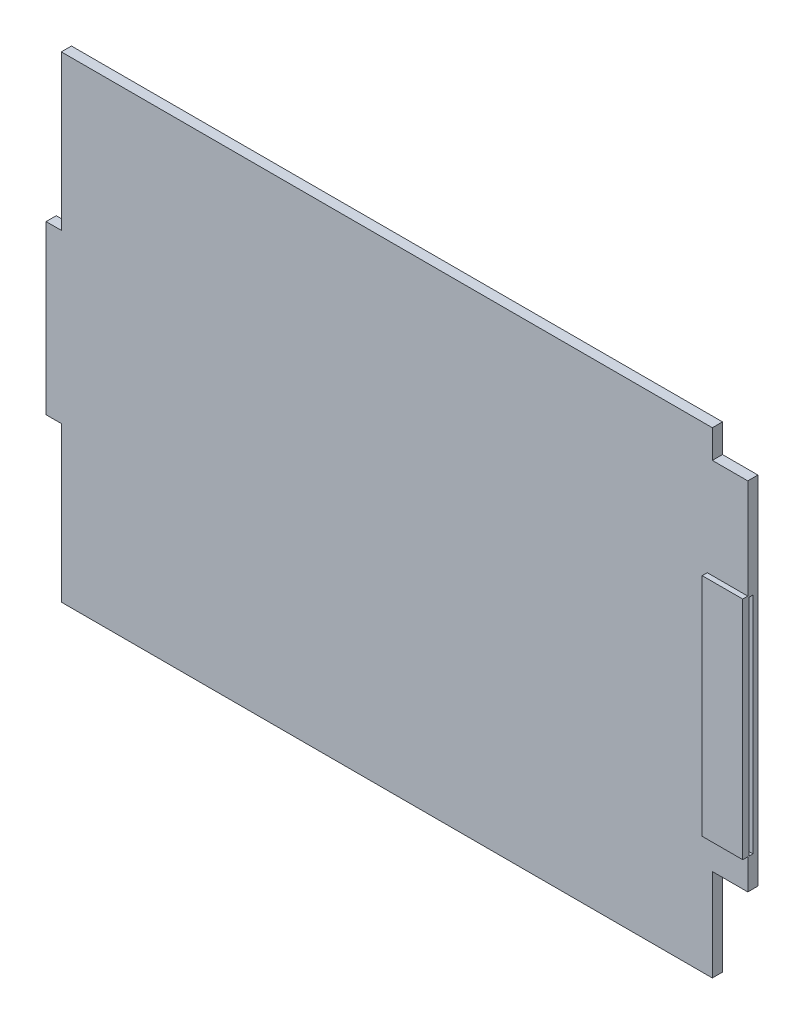
from build123d import *

# Parameters (mm, degrees)
BOSS_EXTRU_1_DEPTH      = 1
ESQUISSE2_W             = 4
ESQUISSE2_H             = 22.100446083
ENL_V_MAT_EXTRU_2_DEPTH = 0.5
ESQUISSE3_W             = 4
ESQUISSE3_H             = 22.262802535
BOSS_EXTRU_2_DEPTH      = 0.5
BOSS_EXTRU_2_DEPTH_BACK = 0.1


with BuildPart() as part:
    # Esquisse1 → Boss.-Extru.1 (new body)
    with BuildSketch(Plane.XY):
        Polygon((34.6, 20.706521175), (31.104320123, 20.706521175), (31.104320123, 23.497793163), (-33.095389285, 23.497793163), (-33.095389285, 8.252206837), (-34.510836618, 8.252206837), (-34.6, 8.252206837), (-34.6, -8.247793163), (-33.095389285, -8.247793163), (-33.095389285, -23.497793163), (31.104320123, -23.497793163), (31.104320123, -14.402052139), (34.6, -14.402052139), align=None)
    extrude(amount=BOSS_EXTRU_1_DEPTH)

    # Esquisse2 → Enlèv. mat.-Extru.2 (cut)
    with BuildSketch(Plane.XY.offset(1)):
        with Locations((32.6, -0.347632361)):
            Rectangle(ESQUISSE2_W, ESQUISSE2_H)
    extrude(amount=-ENL_V_MAT_EXTRU_2_DEPTH, mode=Mode.SUBTRACT)

    # Esquisse3 → Boss.-Extru.2 (add, two sides)
    with BuildSketch(Plane.XY.offset(1)) as boss_extru_2_sk:
        with Locations((32.6, -0.266454134)):
            Rectangle(ESQUISSE3_W, ESQUISSE3_H)
    extrude(amount=BOSS_EXTRU_2_DEPTH)
    extrude(boss_extru_2_sk.sketch, amount=-BOSS_EXTRU_2_DEPTH_BACK)


solid = part.part
